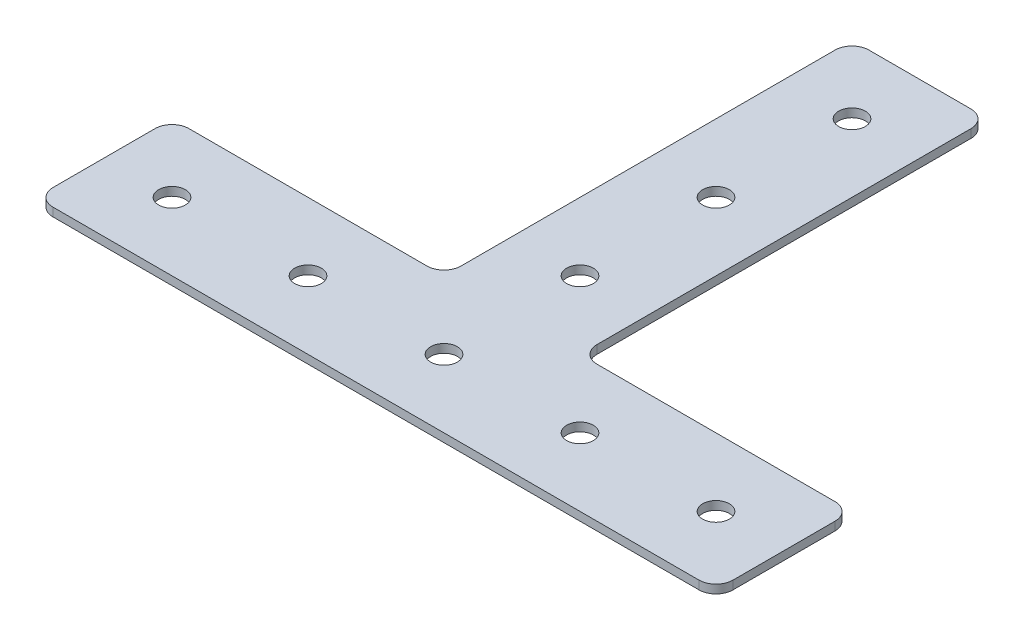
from build123d import *

# Parameters (mm, degrees)
BOSS_EXTRUDE1_DEPTH     = 1.5875
SKETCH2_R               = 2.4892
CUT_EXTRUDE1_DEPTH      = 1
CUT_EXTRUDE1_DEPTH_BACK = 2.5875
FILLET1_R               = 3.175


with BuildPart() as part:
    # Sketch1 → Boss-Extrude1 (new body)
    with BuildSketch(Plane(origin=(0, 0, 0), x_dir=(1, 0, 0), z_dir=(0, 1, 0))):
        Polygon((12.7, 12.7), (63.5, 12.7), (63.5, -12.7), (-63.5, -12.7), (-63.5, 12.7), (-12.7, 12.7), (-12.7, 88.9), (12.7, 88.9), align=None)
    extrude(amount=BOSS_EXTRUDE1_DEPTH)

    # Sketch2 → Cut-Extrude1 (cut, two sides)
    with BuildSketch(Plane(origin=(0, 1.5875, 0), x_dir=(1, 0, 0), z_dir=(0, 1, 0))) as cut_extrude1_sk:
        Circle(SKETCH2_R)
        with Locations((0, 25.4)):
            Circle(SKETCH2_R)
        with Locations((0, 50.8)):
            Circle(SKETCH2_R)
        with Locations((0, 76.2)):
            Circle(SKETCH2_R)
        with Locations((-25.4, 0)):
            Circle(SKETCH2_R)
        with Locations((-50.8, 0)):
            Circle(SKETCH2_R)
        with Locations((25.4, 0)):
            Circle(SKETCH2_R)
        with Locations((50.8, 0)):
            Circle(SKETCH2_R)
    extrude(amount=CUT_EXTRUDE1_DEPTH, mode=Mode.SUBTRACT)
    extrude(cut_extrude1_sk.sketch, amount=-CUT_EXTRUDE1_DEPTH_BACK, mode=Mode.SUBTRACT)

    # Fillet1
    fillet1_edges = [part.edges().sort_by_distance(p)[0] for p in [
        (63.5, 0.79375, 12.7),
        (-63.5, 0.79375, 12.7),
        (-63.5, 0.79375, -12.7),
        (-12.7, 0.79375, -12.7),
        (-12.7, 0.79375, -88.9),
        (12.7, 0.79375, -88.9),
        (12.7, 0.79375, -12.7),
        (63.5, 0.79375, -12.7),
    ]]
    fillet(fillet1_edges, radius=FILLET1_R)


solid = part.part
